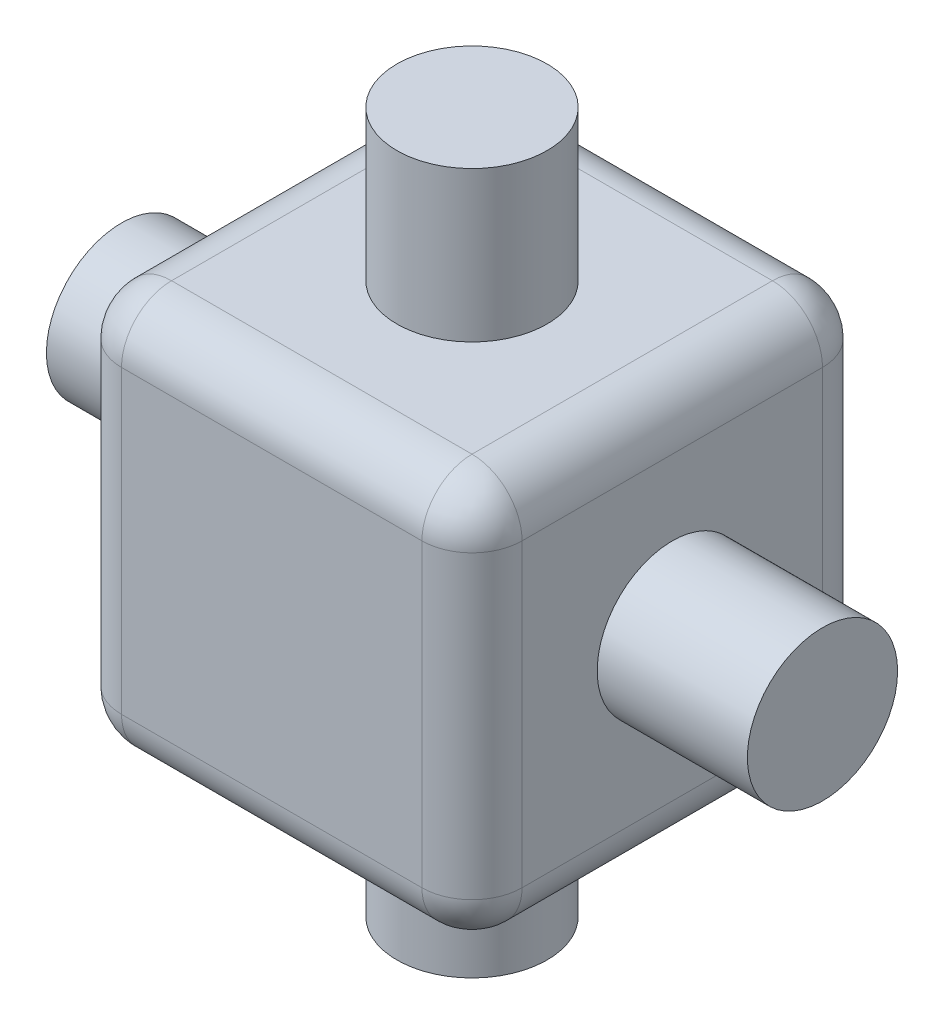
from build123d import *

# Parameters (mm, degrees)
SKETCH1_W           = 8
SKETCH1_H           = 8
BOSS_EXTRUDE1_DEPTH = 8
SKETCH2_R           = 1.5
BOSS_EXTRUDE2_DEPTH = 3
SKETCH3_R           = 1.5
BOSS_EXTRUDE3_DEPTH = 3
SKETCH4_R           = 1.5
BOSS_EXTRUDE4_DEPTH = 3
SKETCH5_R           = 1.5
BOSS_EXTRUDE5_DEPTH = 3
FILLET3_R           = 1
FILLET4_R           = 1
FILLET5_R           = 1
FILLET6_R           = 1
FILLET7_R           = 1
FILLET8_R           = 1


with BuildPart() as part:
    # Sketch1 → Boss-Extrude1 (new body)
    with BuildSketch(Plane.XY):
        Rectangle(SKETCH1_W, SKETCH1_H)
    extrude(amount=BOSS_EXTRUDE1_DEPTH)

    # Sketch2 → Boss-Extrude2 (add)
    with BuildSketch(Plane(origin=(0, 4, 0), x_dir=(1, 0, 0), z_dir=(0, 1, 0))):
        with Locations((0, -4)):
            Circle(SKETCH2_R)
    extrude(amount=BOSS_EXTRUDE2_DEPTH)

    # Sketch3 → Boss-Extrude3 (add)
    with BuildSketch(Plane(origin=(4, 0, 0), x_dir=(0, 0, -1), z_dir=(1, 0, 0))):
        with Locations((-4, 0)):
            Circle(SKETCH3_R)
    extrude(amount=BOSS_EXTRUDE3_DEPTH)

    # Sketch4 → Boss-Extrude4 (add)
    with BuildSketch(Plane.XZ.offset(4)):
        with Locations((0, 4)):
            Circle(SKETCH4_R)
    extrude(amount=BOSS_EXTRUDE4_DEPTH)

    # Sketch5 → Boss-Extrude5 (add)
    with BuildSketch(Plane.ZY.offset(4)):
        with Locations((4, 0)):
            Circle(SKETCH5_R)
    extrude(amount=BOSS_EXTRUDE5_DEPTH)

    # Fillet3
    fillet3_edges = [part.edges().sort_by_distance(p)[0] for p in [
        (4, 0, 0),
    ]]
    fillet(fillet3_edges, radius=FILLET3_R)

    # Fillet4
    fillet4_edges = [part.edges().sort_by_distance(p)[0] for p in [
        (-4, 0, 0),
    ]]
    fillet(fillet4_edges, radius=FILLET4_R)

    # Fillet5
    fillet5_edges = [part.edges().sort_by_distance(p)[0] for p in [
        (-4, 0, 8),
    ]]
    fillet(fillet5_edges, radius=FILLET5_R)

    # Fillet6
    fillet6_edges = [part.edges().sort_by_distance(p)[0] for p in [
        (4, 0, 8),
    ]]
    fillet(fillet6_edges, radius=FILLET6_R)

    # Fillet7
    fillet7_edges = [part.edges().sort_by_distance(p)[0] for p in [
        (0, -4, 0),
        (-4, -4, 4),
        (0, -4, 8),
        (4, -4, 4),
    ]]
    fillet(fillet7_edges, radius=FILLET7_R)

    # Fillet8
    fillet8_edges = [part.edges().sort_by_distance(p)[0] for p in [
        (0, 4, 0),
        (-4, 4, 4),
        (0, 4, 8),
        (4, 4, 4),
    ]]
    fillet(fillet8_edges, radius=FILLET8_R)


solid = part.part
